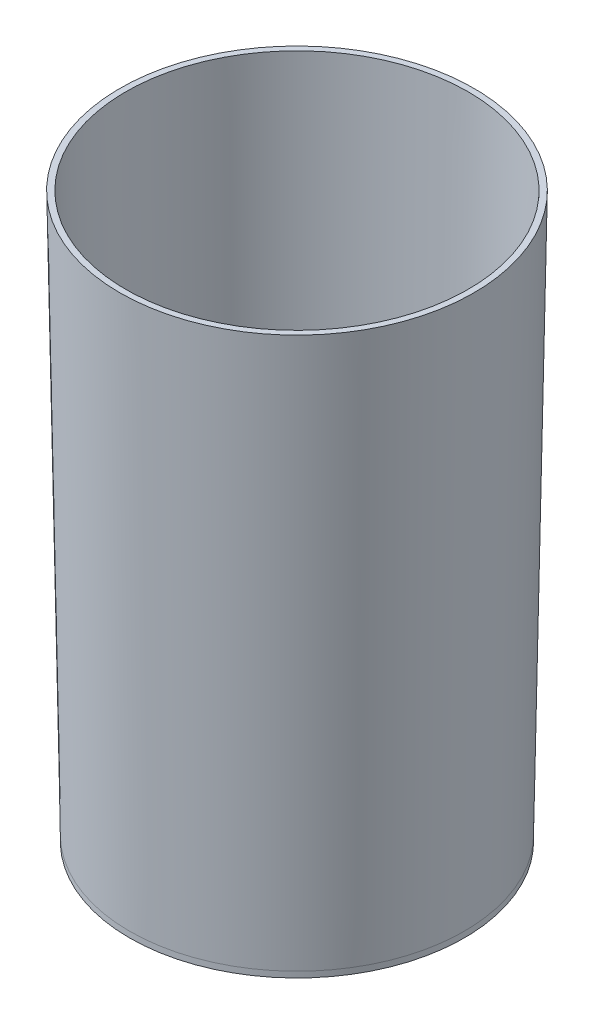
from build123d import *

# Parameters (mm, degrees)
SKETCH1_R           = 57.15
BOSS_EXTRUDE1_DEPTH = 190.5
BOSS_EXTRUDE1_TAPER = -1
SKETCH3_R           = 55.15
CUT_EXTRUDE1_DEPTH  = 190.5
CUT_EXTRUDE1_TAPER  = -1
SKETCH4_R           = 57.15
BOSS_EXTRUDE2_DEPTH = 2


with BuildPart() as part:
    # Sketch1 → Boss-Extrude1 (new body)
    with BuildSketch(Plane(origin=(0, 0, 0), x_dir=(1, 0, 0), z_dir=(0, 1, 0))):
        Circle(SKETCH1_R)
    extrude(amount=BOSS_EXTRUDE1_DEPTH, taper=BOSS_EXTRUDE1_TAPER)

    # Sketch3 → Cut-Extrude1 (cut)
    with BuildSketch(Plane.XZ):
        Circle(SKETCH3_R)
    extrude(amount=-CUT_EXTRUDE1_DEPTH, taper=CUT_EXTRUDE1_TAPER, mode=Mode.SUBTRACT)

    # Sketch4 → Boss-Extrude2 (add)
    with BuildSketch(Plane.XZ):
        Circle(SKETCH4_R)
    extrude(amount=BOSS_EXTRUDE2_DEPTH)


solid = part.part
